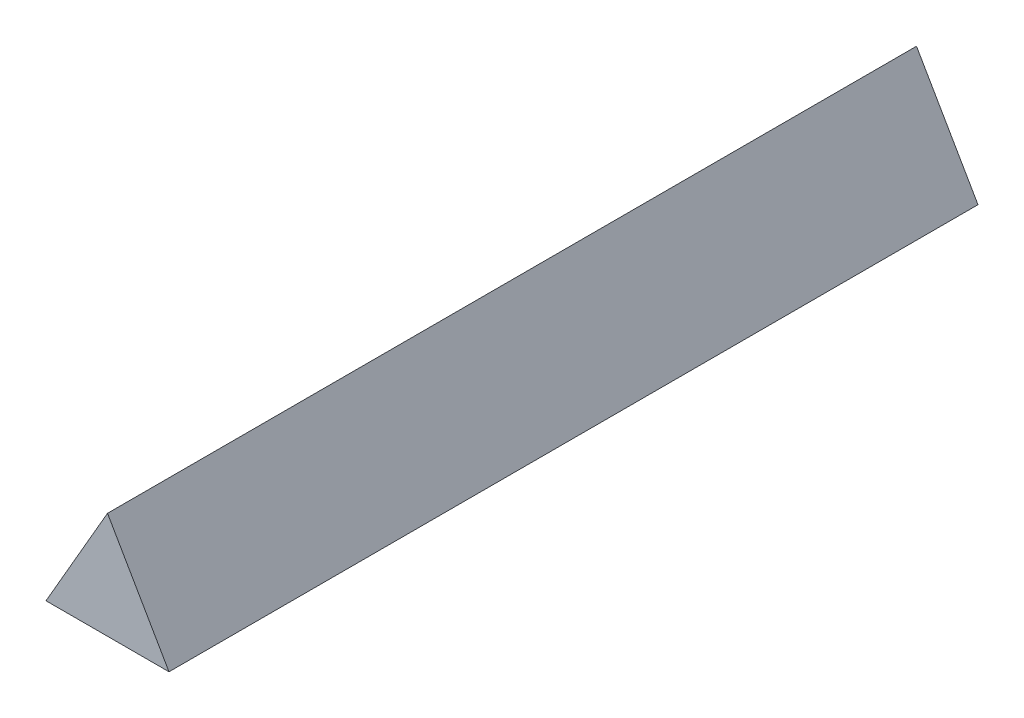
from build123d import *

# Parameters (mm, degrees)
BOSS_EXTRUDE1_DEPTH = 60


with BuildPart() as part:
    # Sketch1 → Boss-Extrude1 (new body)
    with BuildSketch(Plane.XY):
        Polygon((4.561067127, 0), (0, 7.9), (-4.561067127, 0), align=None)
    extrude(amount=BOSS_EXTRUDE1_DEPTH)


solid = part.part
